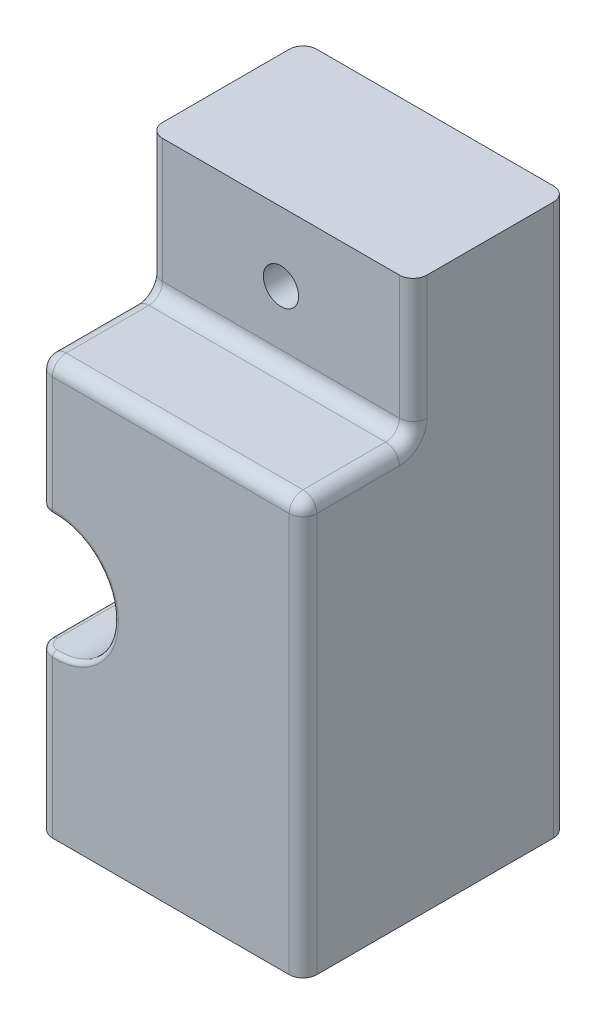
from build123d import *

# Parameters (mm, degrees)
SKETCH1_W                        = 15.24
SKETCH1_H                        = 15.24
BOSS_EXTRUDE1_DEPTH              = 31.75
FILLET1_R                        = 0.79375
CUT_EXTRUDE1_DEPTH               = 37.033102836
SKETCH2_3_W                      = 15.24
SKETCH2_3_H                      = 7.9375
CUT_EXTRUDE2_DEPTH               = 6.35
F_4_0_209_DIAMETER_HOLE1_D       = 2.032
F_4_0_209_DIAMETER_HOLE1_DEPTH   = 6.35
F_4_0_209_DIAMETER_HOLE1_TIP     = 0.610474389
F_10_0_1935_DIAMETER_HOLE1_D     = 3.556
F_10_0_1935_DIAMETER_HOLE1_DEPTH = 6.35
F_10_0_1935_DIAMETER_HOLE1_TIP   = 1.068330181
FILLET2_R                        = 0.79375
FILLET3_R                        = 0.254


with BuildPart() as part:
    # Sketch1 → Boss-Extrude1 (new body)
    with BuildSketch(Plane(origin=(0, 0, 0), x_dir=(1, 0, 0), z_dir=(0, 1, 0))):
        Rectangle(SKETCH1_W, SKETCH1_H)
    extrude(amount=BOSS_EXTRUDE1_DEPTH)

    # Fillet1
    fillet1_edges = [part.edges().sort_by_distance(p)[0] for p in [
        (-7.62, 15.875, 7.62),
        (7.62, 15.875, -7.62),
        (-7.62, 15.875, -7.62),
        (7.62, 15.875, 7.62),
    ]]
    fillet(fillet1_edges, radius=FILLET1_R)

    # Sketch2 → Cut-Extrude1 (cut, through all)
    with BuildSketch(Plane.XY.offset(7.62)):
        with BuildLine():
            Line((-7.62, 16.002), (-7.62, 9.398))
            ThreePointArc((-7.62, 9.398), (-3.266426044, 12.7), (-7.62, 16.002))
        make_face()
    extrude(amount=-CUT_EXTRUDE1_DEPTH, mode=Mode.SUBTRACT)

    # Sketch2_3 → Cut-Extrude2 (cut)
    with BuildSketch(Plane.XY.offset(7.62)):
        with Locations((0, 27.78125)):
            Rectangle(SKETCH2_3_W, SKETCH2_3_H)
    extrude(amount=-CUT_EXTRUDE2_DEPTH, mode=Mode.SUBTRACT)

    # 4 _0.209_ Diameter Hole1
    with Locations(Plane.XY.offset(1.27)):
        with Locations((0, 27.78125)):
            Hole(F_4_0_209_DIAMETER_HOLE1_D / 2, depth=F_4_0_209_DIAMETER_HOLE1_DEPTH)
            with Locations((0, 0, -(F_4_0_209_DIAMETER_HOLE1_DEPTH + F_4_0_209_DIAMETER_HOLE1_TIP / 2))):  # 118° drill point
                Cone(0, F_4_0_209_DIAMETER_HOLE1_D / 2, F_4_0_209_DIAMETER_HOLE1_TIP, mode=Mode.SUBTRACT)

    # 10 _0.1935_ Diameter Hole1
    with Locations(Plane(origin=(0, 0, 0), x_dir=(-1, 0, 0), z_dir=(0, -1, 0))):
        with Locations((0, 0)):
            Hole(F_10_0_1935_DIAMETER_HOLE1_D / 2, depth=F_10_0_1935_DIAMETER_HOLE1_DEPTH)
            with Locations((0, 0, -(F_10_0_1935_DIAMETER_HOLE1_DEPTH + F_10_0_1935_DIAMETER_HOLE1_TIP / 2))):  # 118° drill point
                Cone(0, F_10_0_1935_DIAMETER_HOLE1_D / 2, F_10_0_1935_DIAMETER_HOLE1_TIP, mode=Mode.SUBTRACT)

    # Fillet2
    fillet2_edges = [part.edges().sort_by_distance(p)[0] for p in [
        (7.62, 27.78125, 1.27),
        (-7.62, 27.78125, 1.27),
        (0, 23.8125, 7.62),
        (-7.387516008, 23.8125, 7.387516008),
        (-7.62, 23.8125, 4.048125),
        (0, 23.8125, 1.27),
        (7.62, 23.8125, 4.048125),
        (7.387516008, 23.8125, 7.387516008),
    ]]
    fillet(fillet2_edges, radius=FILLET2_R)

    # Fillet3
    fillet3_edges = [part.edges().sort_by_distance(p)[0] for p in [
        (-7.387203472, 9.341505547, -7.387828369),
        (-3.266426044, 12.7, -7.62),
        (-7.387203472, 16.058494453, -7.387828369),
        (-7.62, 16.002, 0),
        (-7.387203478, 16.058494452, 7.387828364),
        (-3.266426044, 12.7, 7.62),
        (-7.387203478, 9.341505548, 7.387828364),
        (-7.62, 9.398, 0),
    ]]
    fillet(fillet3_edges, radius=FILLET3_R)


solid = part.part
